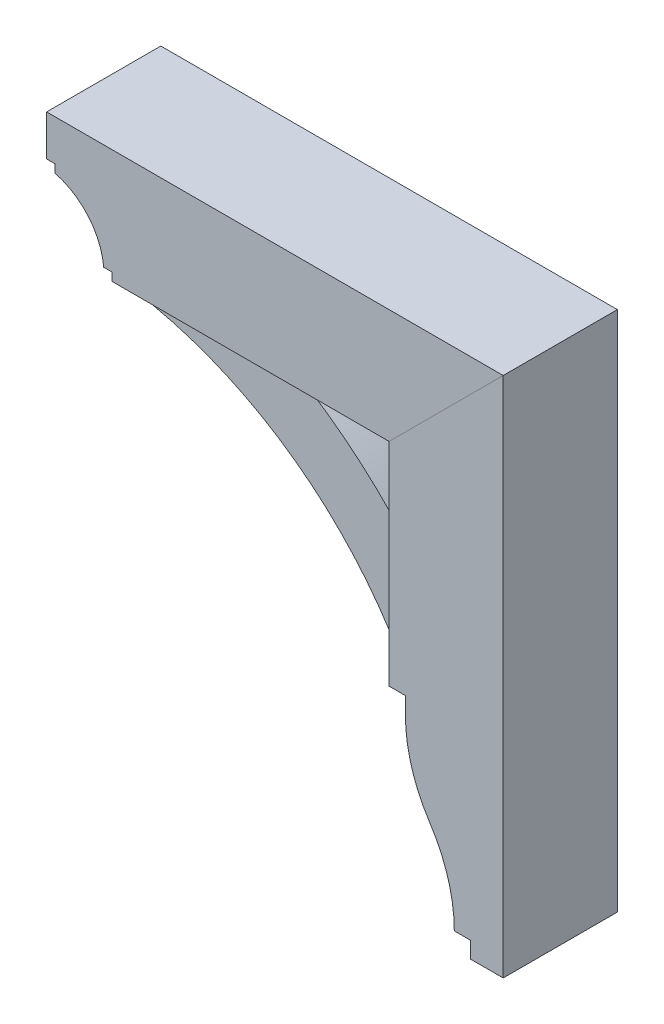
from build123d import *

# Parameters (mm, degrees)
BOSS_EXTRUDE1_DEPTH = 44.45
BOSS_EXTRUDE2_DEPTH = 31.75
BOSS_EXTRUDE3_DEPTH = 44.45


with BuildPart() as part:
    # Sketch1 → Boss-Extrude1 (new body, symmetric)
    with BuildSketch(Plane.XY):
        with BuildLine():
            Line((-26.168776984, 32.385), (-26.168776984, 38.735))
            Line((-26.168776984, 38.735), (-32.518776984, 38.735))
            Line((-32.518776984, 38.735), (-32.518776984, 70.485))
            Line((-32.518776984, 70.485), (323.081223016, 70.485))
            Line((323.081223016, 70.485), (234.181223016, -18.415))
            Line((234.181223016, -18.415), (18.281223016, -18.415))
            Line((18.281223016, -18.415), (18.281223016, -12.065))
            Line((18.281223016, -12.065), (11.931223016, -12.065))
            ThreePointArc((11.931223016, -12.065), (-0.060423906, 16.210016924), (-26.168776984, 32.385))
        make_face()
    extrude(amount=BOSS_EXTRUDE1_DEPTH, both=True)


with BuildPart() as body_2:
    # Sketch1_3 → Boss-Extrude2 (new body, symmetric)
    with BuildSketch(Plane.XY):
        with BuildLine():
            ThreePointArc((234.181223016, -91.44), (192.815678027, -51.17251129), (145.281223016, -18.415))
            Line((145.281223016, -18.415), (37.331223016, -18.415))
            Line((37.331223016, -18.415), (37.331223016, -31.115))
            ThreePointArc((37.331223016, -31.115), (142.045295922, -76.288344286), (221.481223016, -158.115))
            Line((221.481223016, -158.115), (234.181223016, -158.115))
            Line((234.181223016, -158.115), (234.181223016, -91.44))
        make_face()
    extrude(amount=BOSS_EXTRUDE2_DEPTH, both=True)


with BuildPart() as body_3:
    # Sketch1_4 → Boss-Extrude3 (new body, symmetric)
    with BuildSketch(Plane.XY):
        with BuildLine():
            Line((323.081223016, -335.915), (323.081223016, 70.485))
            Line((323.081223016, 70.485), (234.181223016, -18.415))
            Line((234.181223016, -18.415), (234.181223016, -183.515))
            Line((234.181223016, -183.515), (246.881223016, -183.515))
            Line((246.881223016, -183.515), (246.881223016, -196.215))
            ThreePointArc((246.881223016, -196.215), (251.768629387, -229.515028089), (266.018608337, -260.006284404))
            ThreePointArc((266.018608337, -260.006284404), (280.138450492, -290.219081757), (284.981223016, -323.215))
            Line((284.981223016, -323.215), (297.681223016, -323.215))
            Line((297.681223016, -323.215), (297.681223016, -335.915))
            Line((297.681223016, -335.915), (323.081223016, -335.915))
        make_face()
    extrude(amount=BOSS_EXTRUDE3_DEPTH, both=True)


solid = Compound([part.part, body_2.part, body_3.part])
